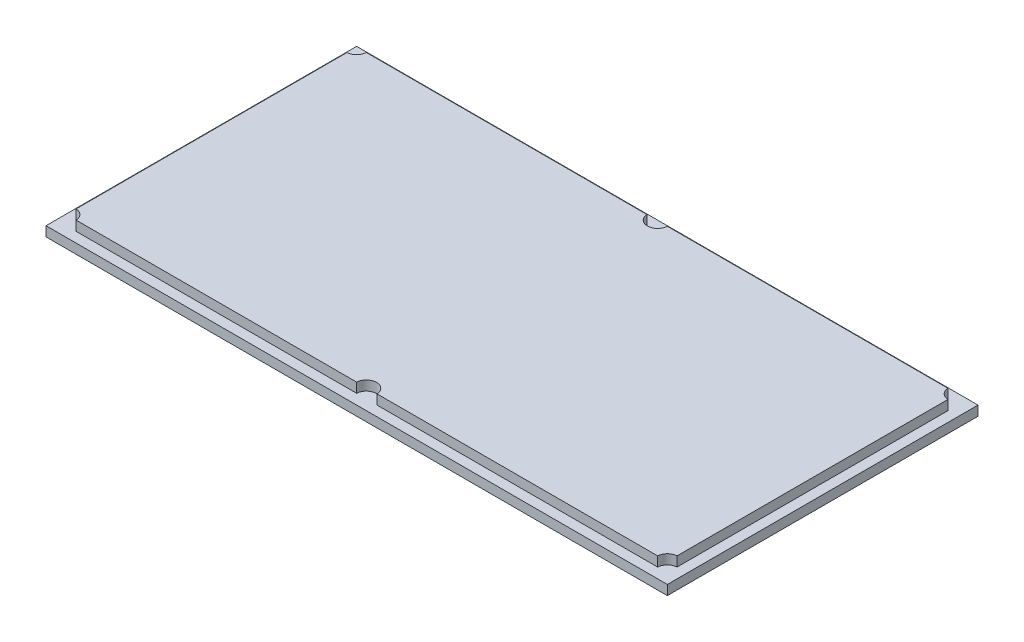
from build123d import *

# Parameters (mm, degrees)
SKETCH3_7_W         = 128
SKETCH3_7_H         = 64
BOSS_EXTRUDE4_DEPTH = 2
BOSS_EXTRUDE6_DEPTH = 4


with BuildPart() as part:
    # Sketch3_7 → Boss-Extrude4 (new body)
    with BuildSketch(Plane(origin=(0, 0, 0), x_dir=(1, 0, 0), z_dir=(0, 1, 0))):
        with Locations((0, -104)):
            Rectangle(SKETCH3_7_W, SKETCH3_7_H)
        with BuildLine():
            Line((-2.097617696, -74.1), (-59.902382304, -74.1))
            ThreePointArc((-59.902382304, -74.1), (-60.51507576, -75.48492424), (-61.9, -76.097617696))
            Line((-61.9, -76.097617696), (-61.9, -131.902382304))
            ThreePointArc((-61.9, -131.902382304), (-60.51507576, -132.51507576), (-59.902382304, -133.9))
            Line((-59.902382304, -133.9), (-2.097617696, -133.9))
            ThreePointArc((-2.097617696, -133.9), (0, -131.9), (2.097617696, -133.9))
            Line((2.097617696, -133.9), (59.902382304, -133.9))
            ThreePointArc((59.902382304, -133.9), (60.51507576, -132.51507576), (61.9, -131.902382304))
            Line((61.9, -131.902382304), (61.9, -76.097617696))
            ThreePointArc((61.9, -76.097617696), (60.51507576, -75.48492424), (59.902382304, -74.1))
            Line((59.902382304, -74.1), (2.097617696, -74.1))
            ThreePointArc((2.097617696, -74.1), (0, -76.1), (-2.097617696, -74.1))
        make_face(mode=Mode.SUBTRACT)
    extrude(amount=BOSS_EXTRUDE4_DEPTH)

    # Sketch3 → Boss-Extrude6 (add)
    with BuildSketch(Plane(origin=(0, 0, 0), x_dir=(1, 0, 0), z_dir=(0, 1, 0))):
        with BuildLine():
            Line((-61.9, -76.097617696), (-61.9, -131.902382304))
            ThreePointArc((-61.9, -131.902382304), (-60.51507576, -132.51507576), (-59.902382304, -133.9))
            Line((-59.902382304, -133.9), (-2.097617696, -133.9))
            ThreePointArc((-2.097617696, -133.9), (0, -131.9), (2.097617696, -133.9))
            Line((2.097617696, -133.9), (59.902382304, -133.9))
            ThreePointArc((59.902382304, -133.9), (60.51507576, -132.51507576), (61.9, -131.902382304))
            Line((61.9, -131.902382304), (61.9, -76.097617696))
            ThreePointArc((61.9, -76.097617696), (60.51507576, -75.48492424), (59.902382304, -74.1))
            Line((59.902382304, -74.1), (2.097617696, -74.1))
            ThreePointArc((2.097617696, -74.1), (0, -76.1), (-2.097617696, -74.1))
            Line((-2.097617696, -74.1), (-59.902382304, -74.1))
            ThreePointArc((-59.902382304, -74.1), (-60.51507576, -75.48492424), (-61.9, -76.097617696))
        make_face()
    extrude(amount=BOSS_EXTRUDE6_DEPTH)


solid = part.part
